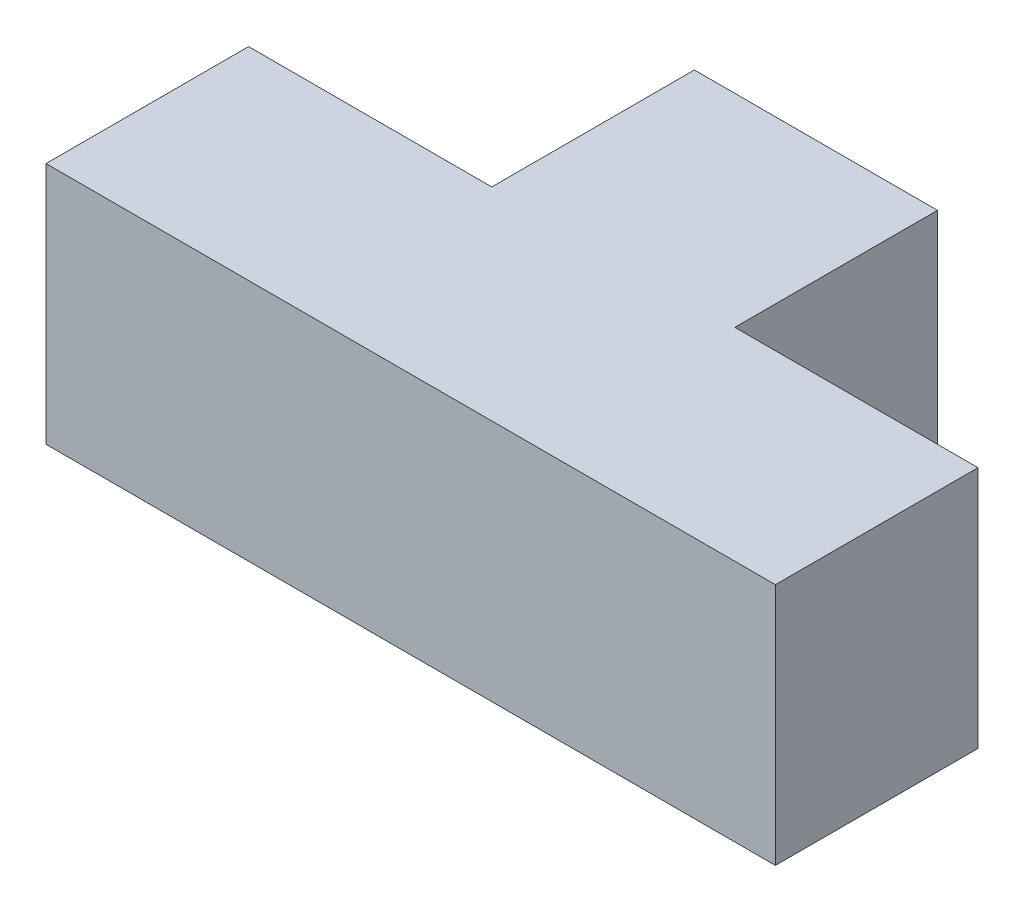
from build123d import *

# Parameters (mm, degrees)
BOSS_EXTRUDE1_DEPTH = 30


with BuildPart() as part:
    # Sketch1 → Boss-Extrude1 (new body)
    with BuildSketch(Plane(origin=(0, 0, 0), x_dir=(1, 0, 0), z_dir=(0, 1, 0))):
        Polygon((0, 0), (-90, 0), (-90, 25), (-60, 25), (-60, 50), (-30, 50), (-30, 25), (0, 25), align=None)
    extrude(amount=BOSS_EXTRUDE1_DEPTH)


solid = part.part
